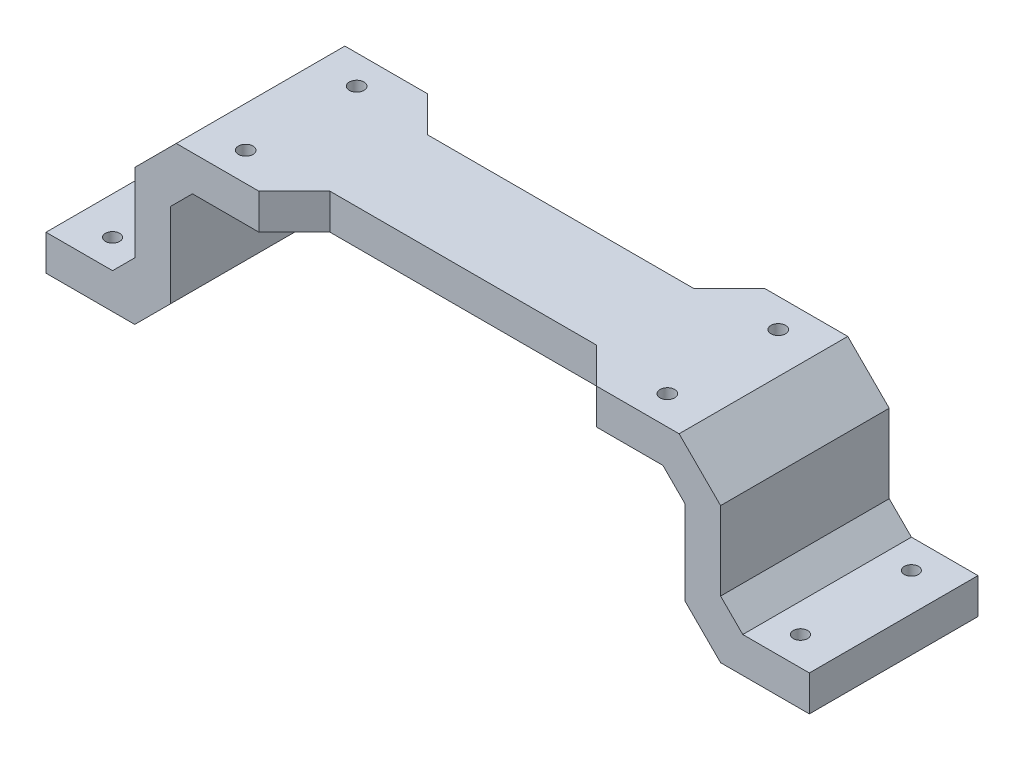
from build123d import *

# Parameters (mm, degrees)
EXTRUDE1_DEPTH     = 46
SKETCH2_R          = 1.6
CUT_EXTRUDE1_DEPTH = 5000
EXTRUDE2_DEPTH     = 8
EXTRUDE3_DEPTH     = 8


with BuildPart() as part:
    # Sketch1 → Extrude1 (new body)
    with BuildSketch(Plane.XY):
        Polygon((-38.5, -40), (-18.5, -40), (-10.5, -32), (-10.5, -13), (-5.5, -8), (100.5, -8), (105.5, -13), (105.5, -32), (113.5, -40), (133.5, -40), (133.5, -32), (118.5, -32), (113.5, -27), (113.5, -9.344202483), (104.155797517, 0), (-9.155797517, 0), (-18.5, -9.344202483), (-18.5, -27), (-23.5, -32), (-38.5, -32), align=None)
    extrude(amount=-EXTRUDE1_DEPTH)

    # Sketch2 → Cut-Extrude1 (cut)
    with BuildSketch(Plane.XZ.offset(40)):
        with Locations((-30.000001952, -14.5)):
            Circle(SKETCH2_R)
        with Locations((-30.000001952, -39.5)):
            Circle(SKETCH2_R)
        with Locations((125, -14.5)):
            Circle(SKETCH2_R)
        with Locations((125, -39.5)):
            Circle(SKETCH2_R)
        with BuildLine():
            ThreePointArc((0, -16.15), (1.65, -14.5), (0, -12.85))
            ThreePointArc((0, -12.85), (-1.65, -14.5), (0, -16.15))
        make_face()
        with BuildLine():
            ThreePointArc((0, -41.15), (1.65, -39.5), (0, -37.85))
            ThreePointArc((0, -37.85), (-1.65, -39.5), (0, -41.15))
        make_face()
        with BuildLine():
            ThreePointArc((95, -16.15), (96.65, -14.5), (95, -12.85))
            ThreePointArc((95, -12.85), (93.35, -14.5), (95, -16.15))
        make_face()
        with BuildLine():
            ThreePointArc((95, -41.15), (96.65, -39.5), (95, -37.85))
            ThreePointArc((95, -37.85), (93.35, -39.5), (95, -41.15))
        make_face()
    extrude(amount=-CUT_EXTRUDE1_DEPTH, mode=Mode.SUBTRACT)

    # Sketch3 → Extrude2 (cut)
    with BuildSketch(Plane.XY):
        Polygon((-38.5, -32), (-38.5, -40), (-18.5, -40), (-10.5, -32), (-10.5, -13), (-5.5, -8), (100.5, -8), (105.5, -13), (105.5, -32), (113.5, -40), (133.5, -40), (133.5, -32), (118.5, -32), (113.5, -27), (113.5, -9.344202483), (104.155797517, 0), (-9.155797517, 0), (-18.5, -9.344202483), (-18.5, -27), (-23.5, -32), align=None)
    extrude(amount=-EXTRUDE2_DEPTH, mode=Mode.SUBTRACT)

    # Sketch4 → Extrude3 (cut)
    with BuildSketch(Plane(origin=(0, 0, 0), x_dir=(1, 0, 0), z_dir=(0, 1, 0))):
        Polygon((9.5, 46), (17.5, 38), (77.5, 38), (85.5, 46), align=None)
        Polygon((85.5, 8), (9.5, 8), (17.5, 16), (77.5, 16), align=None)
    extrude(amount=-EXTRUDE3_DEPTH, mode=Mode.SUBTRACT)


solid = part.part
